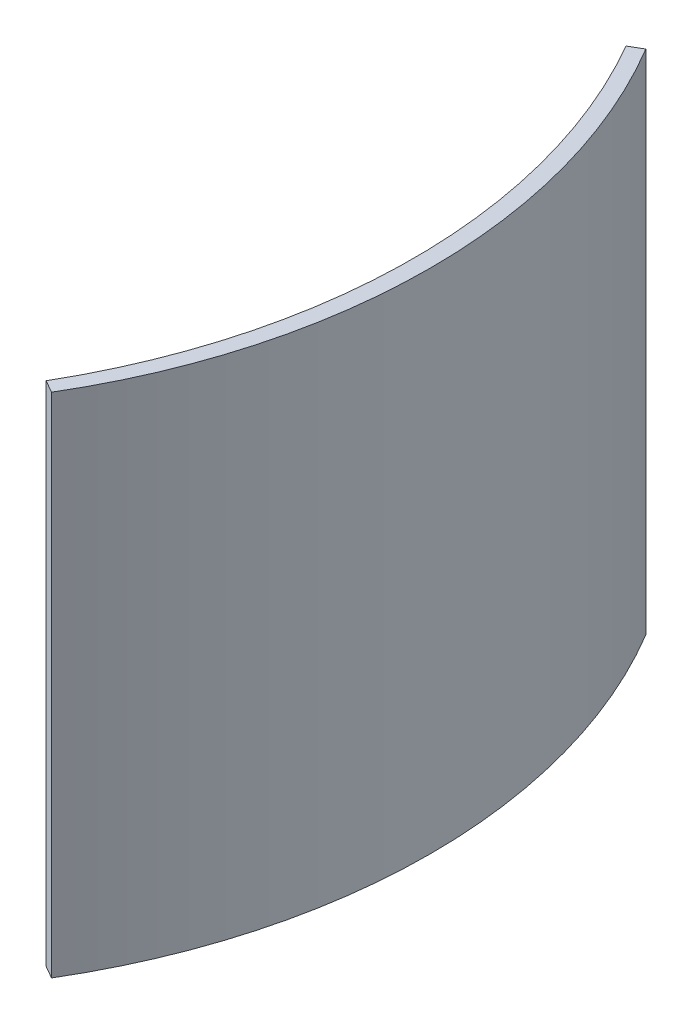
from build123d import *

# Parameters (mm, degrees)
BOSS_EXTRUDE1_DEPTH = 35


with BuildPart() as part:
    # Sketch1 → Boss-Extrude1 (new body)
    with BuildSketch(Plane(origin=(0, 0, 0), x_dir=(1, 0, 0), z_dir=(0, 1, 0))):
        with BuildLine():
            Line((0, 0), (0.866025404, 0.5))
            ThreePointArc((0.866025404, 0.5), (6.518536413, -20), (0.866025404, -40.5))
            Line((0.866025404, -40.5), (0, -40))
            ThreePointArc((0, -40), (5.358983849, -20), (0, 0))
        make_face()
    extrude(amount=BOSS_EXTRUDE1_DEPTH)


solid = part.part
